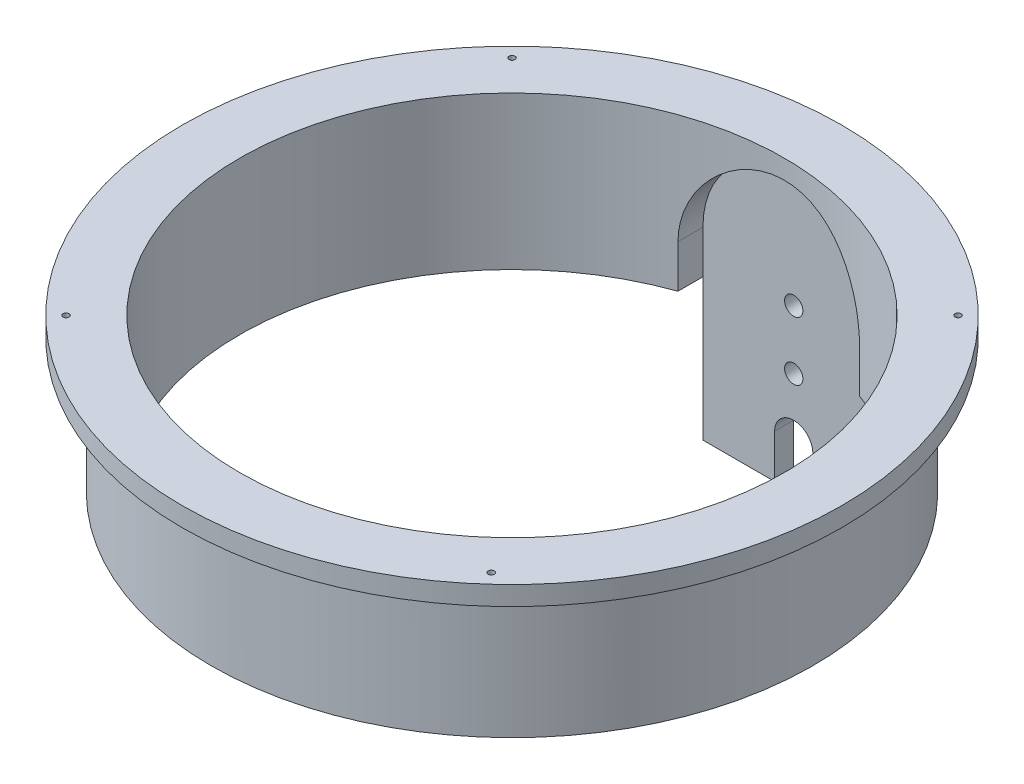
from build123d import *

# Parameters (mm, degrees)
CUT_EXTRUDE1_START        = -45.212
CUT_EXTRUDE1_DEPTH        = 3.302
CUT_EXTRUDE1_DEPTH_BACK   = 1.5875
SKETCH4_W                 = 30.1625
SKETCH4_H                 = 23.495
BOSS_EXTRUDE1_DEPTH       = 3.175
SKETCH5_R                 = 1.524
CUT_EXTRUDE2_DEPTH        = 8.96925
F_1_0MM_DOWEL_HOLE1_D     = 1
F_1_0MM_DOWEL_HOLE1_DEPTH = 3.175


with BuildPart() as part:
    # Sketch2 → Revolve1 (revolve)
    with BuildSketch(Plane.XY):
        Polygon((45.24375, -12.7), (50.00625, -12.7), (50.00625, 9.525), (54.76875, 9.525), (54.76875, 12.7), (50.00625, 12.7), (45.24375, 12.7), align=None)
    revolve(axis=Axis((0, 12.7, 0), (0, -1, 0)))

    # Sketch3 → Cut-Extrude1 (cut, two sides)
    with BuildSketch(Plane.XY.offset(CUT_EXTRUDE1_START)) as cut_extrude1_sk:
        with BuildLine():
            Line((-15.08125, -12.7), (15.08125, -12.7))
            Line((15.08125, -12.7), (15.08125, -5.55625))
            ThreePointArc((15.08125, -5.55625), (0, 9.525), (-15.08125, -5.55625))
            Line((-15.08125, -5.55625), (-15.08125, -12.7))
        make_face()
    extrude(amount=CUT_EXTRUDE1_DEPTH, mode=Mode.SUBTRACT)
    extrude(cut_extrude1_sk.sketch, amount=-CUT_EXTRUDE1_DEPTH_BACK, mode=Mode.SUBTRACT)

    # Sketch4 → Boss-Extrude1 (add)
    with BuildSketch(Plane.XY.offset(-46.7995)):
        with BuildLine():
            ThreePointArc((15.08125, -5.55625), (0, 9.525), (-15.08125, -5.55625))
            Line((-15.08125, -5.55625), (-15.08125, -12.7))
            Line((-15.08125, -12.7), (15.08125, -12.7))
            Line((15.08125, -12.7), (15.08125, -5.55625))
        make_face()
        with Locations((0, -24.4475)):
            Rectangle(SKETCH4_W, SKETCH4_H)
    extrude(amount=-BOSS_EXTRUDE1_DEPTH)

    # Sketch5 → Cut-Extrude2 (cut, through all)
    with BuildSketch(Plane.XY.offset(-46.7995)):
        with Locations((0, -19.0881)):
            Circle(SKETCH5_R)
        with Locations((0, -9.3091)):
            Circle(SKETCH5_R)
        with BuildLine():
            Line((-3.175, -36.195), (-3.175, -28.9687))
            ThreePointArc((-3.175, -28.9687), (0, -25.7937), (3.175, -28.9687))
            Line((3.175, -28.9687), (3.175, -36.195))
            Line((3.175, -36.195), (-3.175, -36.195))
        make_face()
    extrude(amount=-CUT_EXTRUDE2_DEPTH, mode=Mode.SUBTRACT)

    # Ø1.0mm Dowel Hole1
    with Locations(Plane(origin=(0, 9.525, 0), x_dir=(-1, 0, 0), z_dir=(0, -1, 0))):
        with Locations((-35.279486504, -38.727354522), (-37.043556499, 37.043556499), (37.043556499, 37.043556499), (37.043556499, -37.043556499)):
            Hole(F_1_0MM_DOWEL_HOLE1_D / 2, depth=F_1_0MM_DOWEL_HOLE1_DEPTH)


solid = part.part
